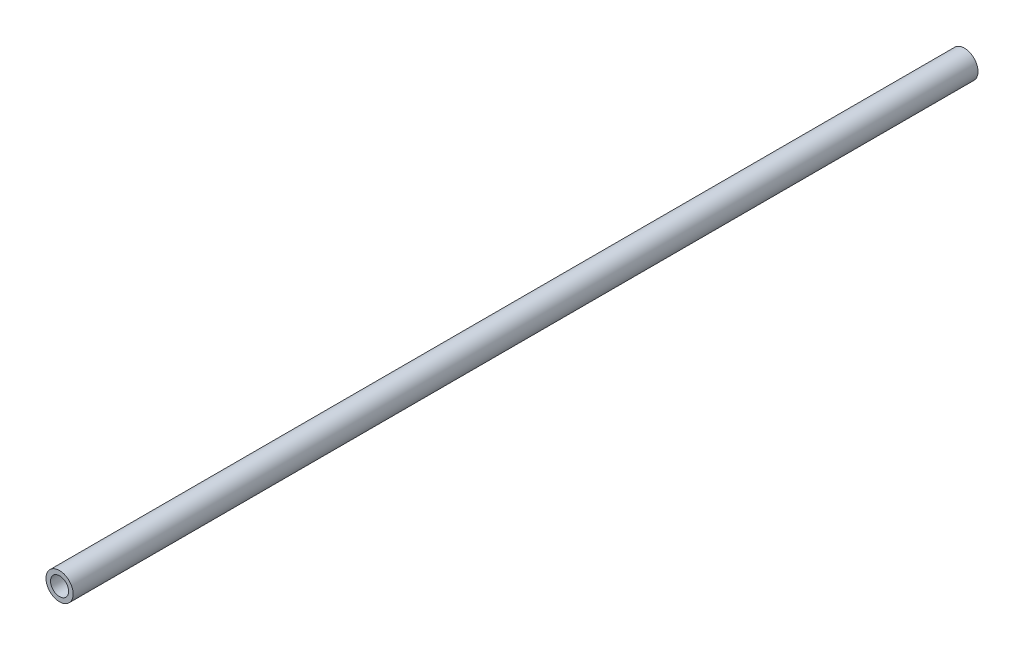
from build123d import *

# Parameters (mm, degrees)
SKETCH1_R           = 7.62
SKETCH1_R_2         = 5.08
BOSS_EXTRUDE1_DEPTH = 508


with BuildPart() as part:
    # Sketch1 → Boss-Extrude1 (new body)
    with BuildSketch(Plane.XY):
        Circle(SKETCH1_R)
        Circle(SKETCH1_R_2, mode=Mode.SUBTRACT)
    extrude(amount=BOSS_EXTRUDE1_DEPTH)


solid = part.part
